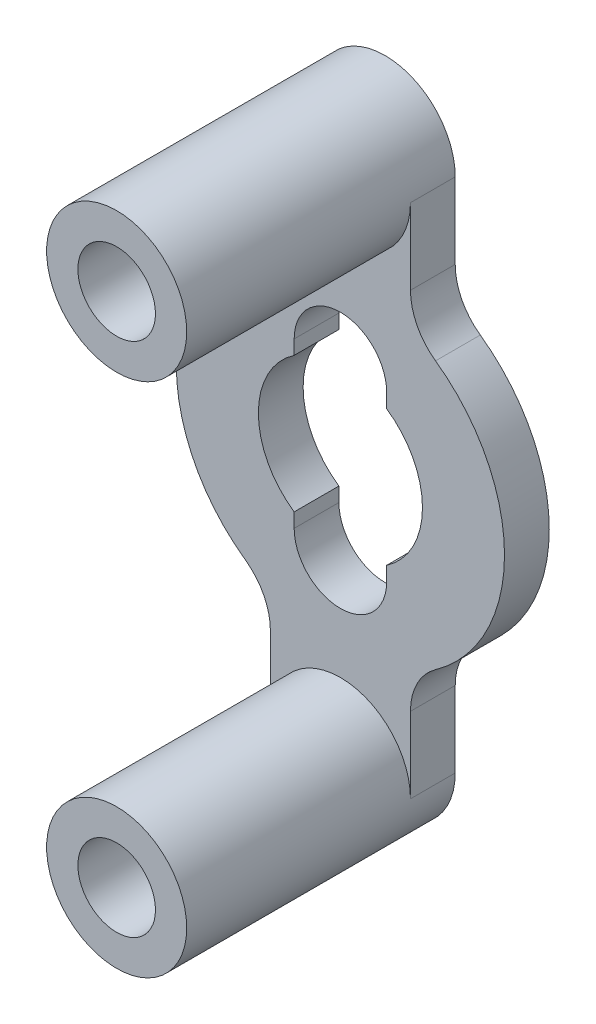
from build123d import *

# Parameters (mm, degrees)
EXTRUDE_1_DEPTH = 1.5
SKETCH_1_4_R    = 2.347892547
SKETCH_1_4_R_2  = 1.3
EXTRUDE_2_DEPTH = 9


with BuildPart() as part:
    # 草图1 → 凸台-拉伸1 (new body)
    with BuildSketch(Plane.XY):
        with BuildLine():
            ThreePointArc((3.188454535, 4.481490565), (2.570411742, 5.19430182), (2.347892547, 6.111123497))
            Line((2.347892547, 6.111123497), (2.347892547, 8.652107453))
            ThreePointArc((2.347892547, 8.652107453), (0, 6.304214905), (-2.347892547, 8.652107453))
            Line((-2.347892547, 8.652107453), (-2.347892547, 6.111123497))
            ThreePointArc((-2.347892547, 6.111123497), (-2.570411742, 5.19430182), (-3.188454535, 4.481490565))
            ThreePointArc((-3.188454535, 4.481490565), (-5.5, 0), (-3.188454535, -4.481490565))
            ThreePointArc((-3.188454535, -4.481490565), (-2.570411742, -5.19430182), (-2.347892547, -6.111123497))
            Line((-2.347892547, -6.111123497), (-2.347892547, -8.652107453))
            ThreePointArc((-2.347892547, -8.652107453), (0, -6.304214905), (2.347892547, -8.652107453))
            Line((2.347892547, -8.652107453), (2.347892547, -6.111123497))
            ThreePointArc((2.347892547, -6.111123497), (2.570411742, -5.19430182), (3.188454535, -4.481490565))
            ThreePointArc((3.188454535, -4.481490565), (5.5, 0), (3.188454535, 4.481490565))
        make_face()
        with BuildLine():
            ThreePointArc((1.55, -2.75), (0, -4.3), (-1.55, -2.75))
            Line((-1.55, -2.75), (-1.55, -2.271563338))
            ThreePointArc((-1.55, -2.271563338), (-2.75, 0), (-1.55, 2.271563338))
            Line((-1.55, 2.271563338), (-1.55, 2.75))
            ThreePointArc((-1.55, 2.75), (0, 4.3), (1.55, 2.75))
            Line((1.55, 2.75), (1.55, 2.271563338))
            ThreePointArc((1.55, 2.271563338), (2.75, 0), (1.55, -2.271563338))
            Line((1.55, -2.271563338), (1.55, -2.75))
        make_face(mode=Mode.SUBTRACT)
    extrude(amount=EXTRUDE_1_DEPTH)

    # 草图1<4> → 凸台-拉伸2 (add)
    # profile 1 of 2: a face of its own
    with BuildSketch(Plane.XY):
        with Locations((0, 8.652107453)):
            Circle(SKETCH_1_4_R)
        with Locations((0, 8.652107453)):
            Circle(SKETCH_1_4_R_2, mode=Mode.SUBTRACT)
    # profile 2 of 2: a face of its own
    with BuildSketch(Plane.XY):
        with Locations((0, -8.652107453)):
            Circle(SKETCH_1_4_R)
        with Locations((0, -8.652107453)):
            Circle(SKETCH_1_4_R_2, mode=Mode.SUBTRACT)
    extrude(amount=EXTRUDE_2_DEPTH)


solid = part.part
